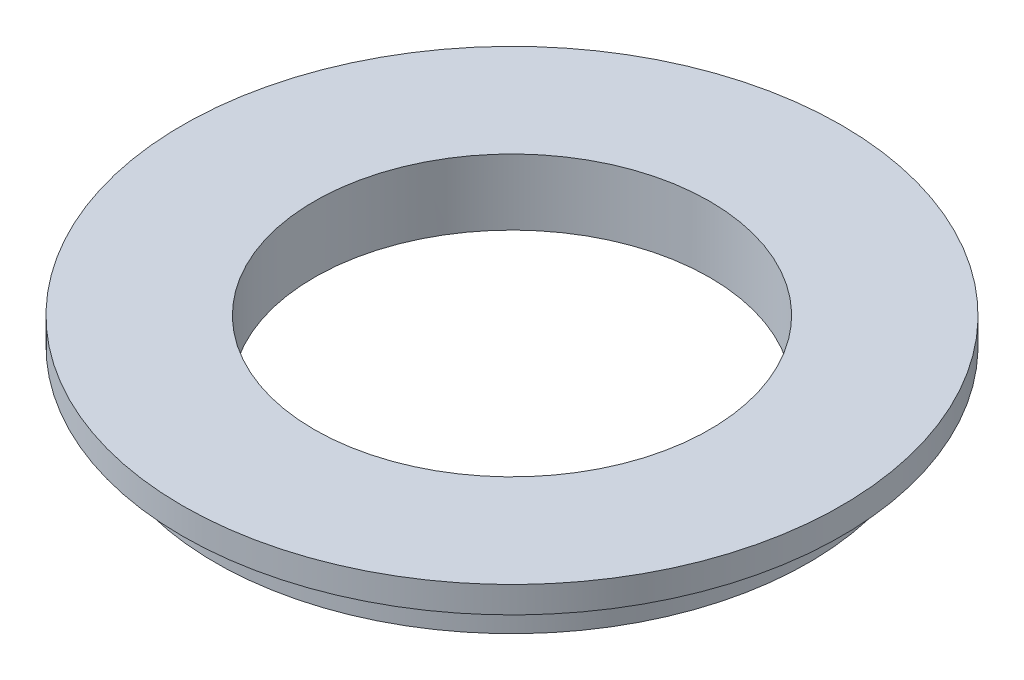
from build123d import *

# Parameters (mm, degrees)
SKETCH1_R           = 25
SKETCH1_R_2         = 15
BOSS_EXTRUDE1_DEPTH = 2
SKETCH2_R           = 22.5
SKETCH2_R_2         = 15
BOSS_EXTRUDE2_DEPTH = 3


with BuildPart() as part:
    # Sketch1 → Boss-Extrude1 (new body)
    with BuildSketch(Plane(origin=(0, 0, 0), x_dir=(1, 0, 0), z_dir=(0, 1, 0))):
        Circle(SKETCH1_R)
        Circle(SKETCH1_R_2, mode=Mode.SUBTRACT)
    extrude(amount=BOSS_EXTRUDE1_DEPTH)

    # Sketch2 → Boss-Extrude2 (add)
    with BuildSketch(Plane.XZ):
        Circle(SKETCH2_R)
        Circle(SKETCH2_R_2, mode=Mode.SUBTRACT)
    extrude(amount=BOSS_EXTRUDE2_DEPTH)


solid = part.part
